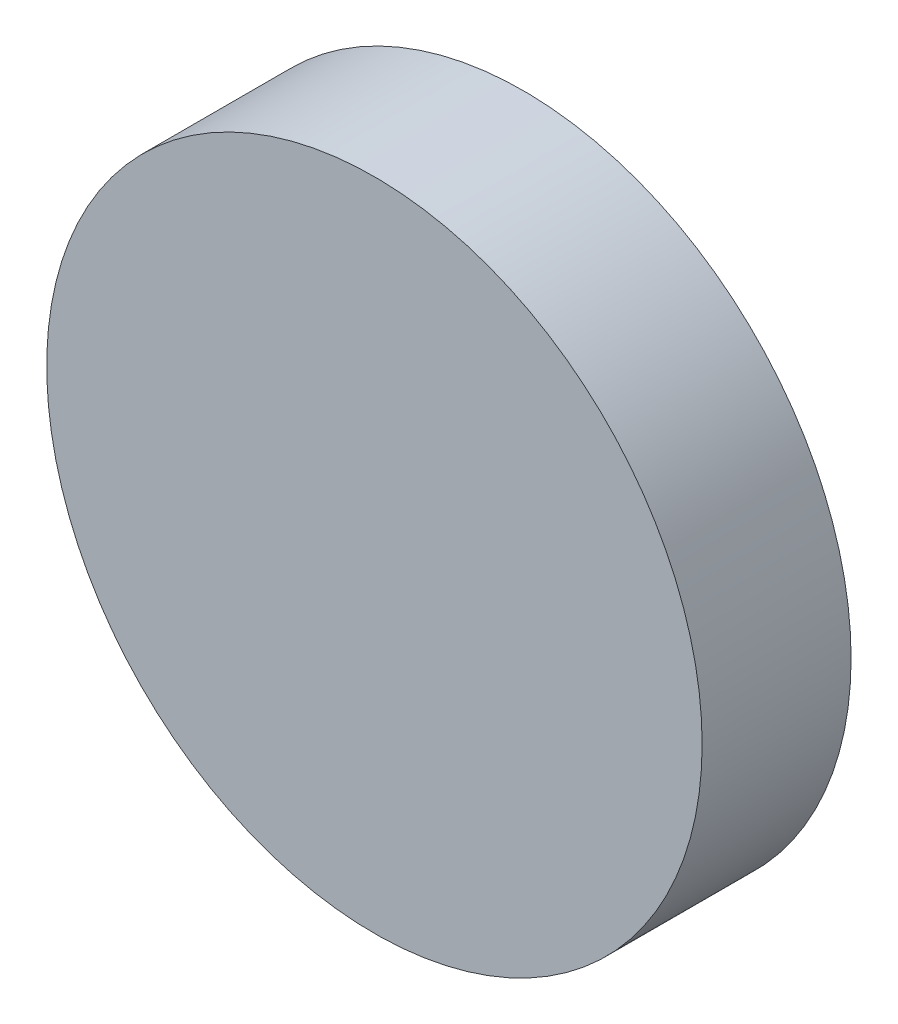
from build123d import *


with BuildPart() as part:
    # Sketch1 → Revolve1 (revolve)
    with BuildSketch(Plane(origin=(0, 0, 0), x_dir=(1, 0, 0), z_dir=(0, 1, 0)), mode=Mode.PRIVATE) as revolve1_sk:
        with BuildLine():
            Line((0, 0), (-22, 0))
            Line((-22, 0), (-22, 10))
            ThreePointArc((-22, 10), (-11.158230372, 12.660356065), (0, 13))
            Line((0, 13), (0, 0))
        make_face()
    revolve(revolve1_sk.sketch.rotate(Axis((0, 0, 0), (0, 0, -1)), 180), axis=Axis((0, 0, 0), (0, 0, -1)))  # turned: the seam where the file's is


solid = part.part
